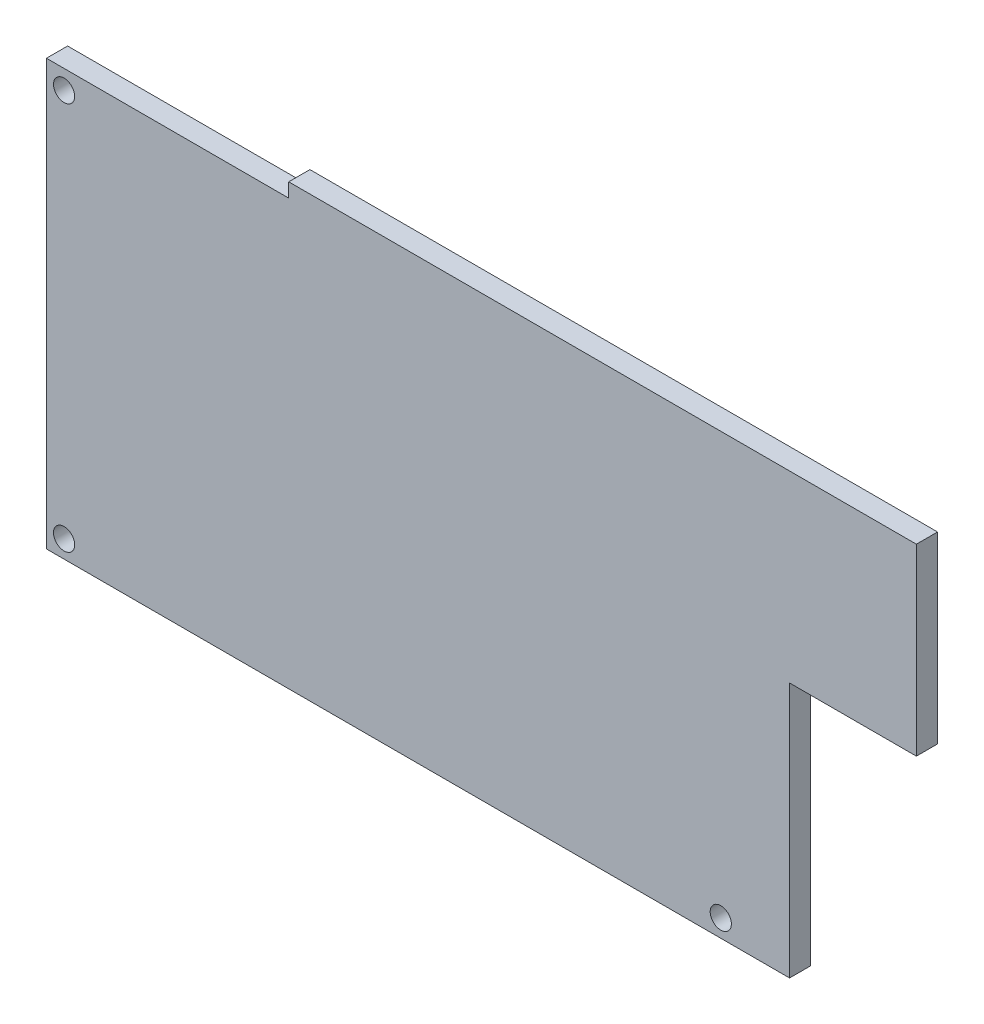
from build123d import *

# Parameters (mm, degrees)
BOSS_EXTRUDE1_DEPTH = 3
SKETCH2_R           = 1.5
CUT_EXTRUDE1_DEPTH  = 10


with BuildPart() as part:
    # Sketch1 → Boss-Extrude1 (new body)
    with BuildSketch(Plane.XY):
        Polygon((119.877392692, -74.229255365), (30.990803074, -74.229255365), (30.990803074, -76.229255365), (-3.323071753, -76.229255365), (-3.323071753, -136.414342305), (101.918179526, -136.414342305), (101.918179526, -100.229255365), (119.877392692, -100.229255365), align=None)
    extrude(amount=BOSS_EXTRUDE1_DEPTH)

    # Sketch2 → Cut-Extrude1 (cut)
    with BuildSketch(Plane(origin=(0, 0, 0), x_dir=(-1, 0, 0), z_dir=(0, 0, -1))):
        with Locations((-92.176928247, -133.914342305)):
            Circle(SKETCH2_R)
        with Locations((0.823071753, -133.914342305)):
            Circle(SKETCH2_R)
        with Locations((0.823071753, -78.914342305)):
            Circle(SKETCH2_R)
    extrude(amount=-CUT_EXTRUDE1_DEPTH, mode=Mode.SUBTRACT)


solid = part.part
